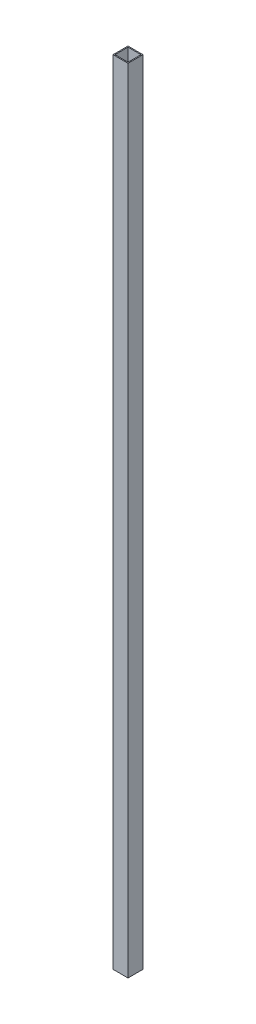
from build123d import *

# Parameters (mm, degrees)
SKETCH2_W           = 30
SKETCH2_H           = 30
SKETCH2_W_2         = 26
SKETCH2_H_2         = 26
BOSS_EXTRUDE1_DEPTH = 793


with BuildPart() as part:
    # Sketch2 → Boss-Extrude1 (new body, symmetric)
    with BuildSketch(Plane(origin=(0, 0, 0), x_dir=(1, 0, 0), z_dir=(0, 1, 0))):
        Rectangle(SKETCH2_W, SKETCH2_H)
        Rectangle(SKETCH2_W_2, SKETCH2_H_2, mode=Mode.SUBTRACT)
    extrude(amount=BOSS_EXTRUDE1_DEPTH, both=True)


solid = part.part
